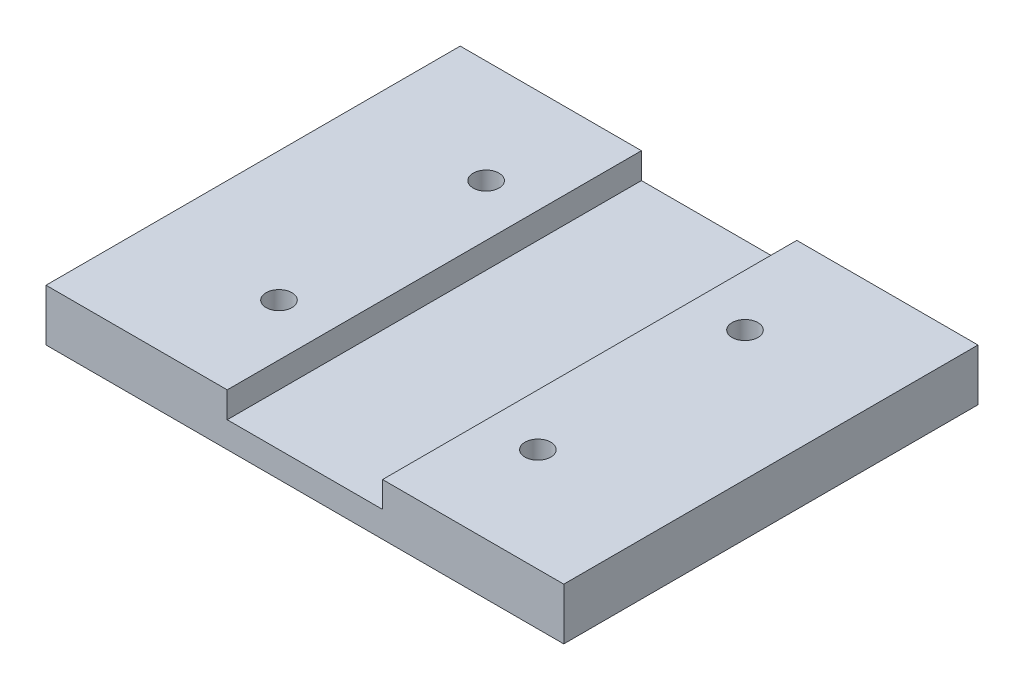
from build123d import *

# Parameters (mm, degrees)
SKETCH1_W               = 2540
SKETCH1_H               = 2032
BOSS_EXTRUDE1_DEPTH     = 254
SKETCH2_W               = 762
SKETCH2_H               = 127
CUT_EXTRUDE1_DEPTH      = 1017
CUT_EXTRUDE1_DEPTH_BACK = 1017
F_5_DIAMETER_HOLE1_D    = 127


with BuildPart() as part:
    # Sketch1 → Boss-Extrude1 (new body)
    with BuildSketch(Plane(origin=(0, 0, 0), x_dir=(1, 0, 0), z_dir=(0, 1, 0))):
        Rectangle(SKETCH1_W, SKETCH1_H)
    extrude(amount=BOSS_EXTRUDE1_DEPTH)

    # Sketch2 → Cut-Extrude1 (cut, two sides)
    with BuildSketch(Plane.XY) as cut_extrude1_sk:
        with Locations((0, 190.5)):
            Rectangle(SKETCH2_W, SKETCH2_H)
    extrude(amount=CUT_EXTRUDE1_DEPTH, mode=Mode.SUBTRACT)
    extrude(cut_extrude1_sk.sketch, amount=-CUT_EXTRUDE1_DEPTH_BACK, mode=Mode.SUBTRACT)

    # 5" Diameter Hole1 (through all)
    with Locations(Plane(origin=(0, 254, 0), x_dir=(1, 0, 0), z_dir=(0, 1, 0))):
        with Locations((-635, 508), (-635, -508)):
            f_5_diameter_hole1 = Hole(F_5_DIAMETER_HOLE1_D / 2)

    # Mirror1: 5" Diameter Hole1 across plane
    add(f_5_diameter_hole1.mirror(Plane(origin=(0, 0, 0), x_dir=(0, 0, 1), z_dir=(1, 0, 0))), mode=Mode.SUBTRACT)


solid = part.part
